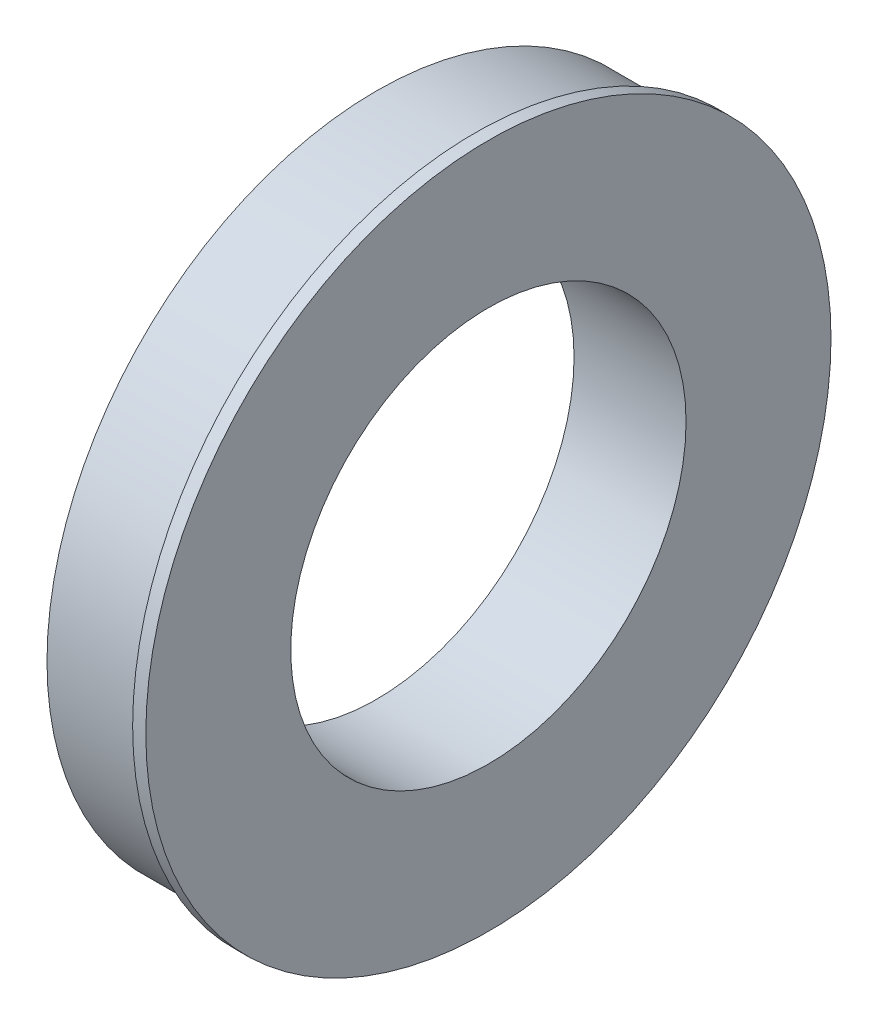
from build123d import *

# Parameters (mm, degrees)
SKETCH2_R           = 63.5
SKETCH2_R_2         = 38.1
BOSS_EXTRUDE1_DEPTH = 19.05
SKETCH3_R           = 66.04
SKETCH3_R_2         = 38.1
BOSS_EXTRUDE2_DEPTH = 2.54


with BuildPart() as part:
    # Sketch2 → Boss-Extrude1 (new body)
    with BuildSketch(Plane(origin=(0, 0, 0), x_dir=(0, 0, -1), z_dir=(1, 0, 0))):
        Circle(SKETCH2_R)
        Circle(SKETCH2_R_2, mode=Mode.SUBTRACT)
    extrude(amount=BOSS_EXTRUDE1_DEPTH)

    # Sketch3 → Boss-Extrude2 (add)
    with BuildSketch(Plane(origin=(19.05, 0, 0), x_dir=(0, 0, -1), z_dir=(1, 0, 0))):
        Circle(SKETCH3_R)
        Circle(SKETCH3_R_2, mode=Mode.SUBTRACT)
    extrude(amount=BOSS_EXTRUDE2_DEPTH)


solid = part.part
